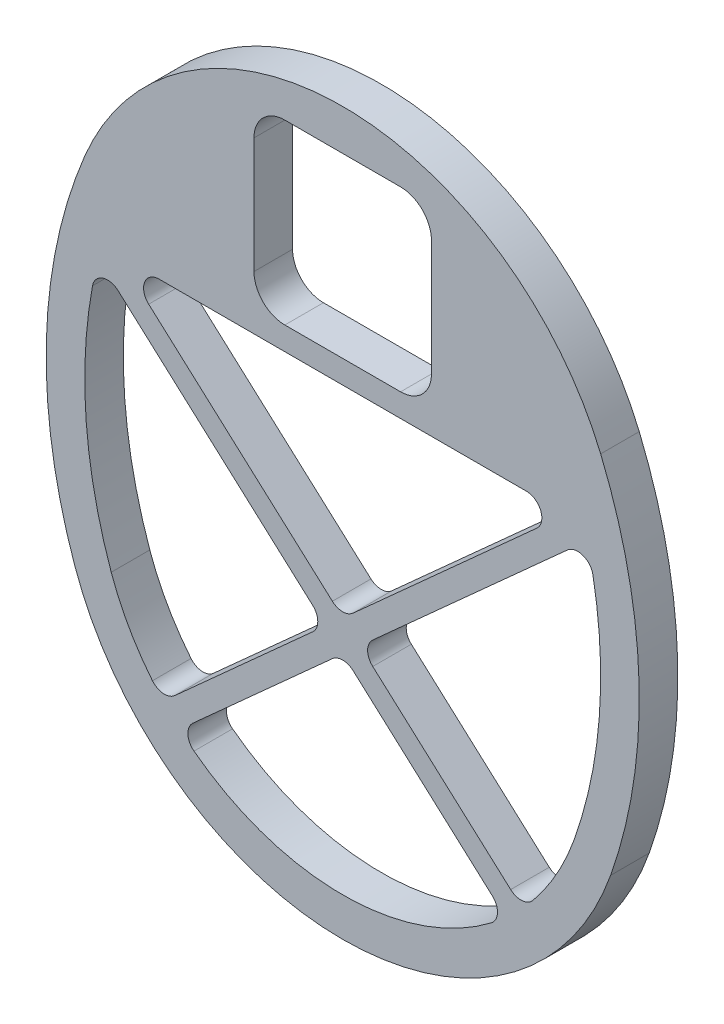
from build123d import *

# Parameters (mm, degrees)
BOSS_EXTRUDE1_DEPTH = 6.35
CUT_EXTRUDE1_REACH  = 8.35
SKETCH2_W           = 29.21
SKETCH2_H           = 29.21
FILLET1_R           = 5.08
BOSS_EXTRUDE2_DEPTH = 6.35
FILLET2_R           = 2.54


with BuildPart() as part:
    # Sketch1 → Boss-Extrude1 (new body)
    with BuildSketch(Plane.XY):
        with BuildLine():
            ThreePointArc((42.457951031, 57.15), (0, 85.455300688), (-42.457951031, 57.15))
            ThreePointArc((-42.457951031, 57.15), (-48.776790726, 27.667949622), (-44.086837414, -2.116666667))
            ThreePointArc((-44.086837414, -2.116666667), (0, -33.290768363), (44.086837414, -2.116666667))
            ThreePointArc((44.086837414, -2.116666667), (48.776790726, 27.667949622), (42.457951031, 57.15))
        make_face()
        with BuildLine():
            ThreePointArc((-38.1, 0), (-42.411411047, 22.737195516), (-39.698659089, 45.72))
            Line((-39.698659089, 45.72), (39.698659089, 45.72))
            ThreePointArc((39.698659089, 45.72), (42.411411047, 22.737195516), (38.1, 0))
            ThreePointArc((38.1, 0), (0, -26.940768363), (-38.1, 0))
        make_face(mode=Mode.SUBTRACT)
    extrude(amount=BOSS_EXTRUDE1_DEPTH)

    # Sketch2 → Cut-Extrude1 (cut, up to next)
    with BuildSketch(Plane.XY.offset(6.35), mode=Mode.PRIVATE) as cut_extrude1_sk1:
        with Locations((0, 64.135)):
            Rectangle(SKETCH2_W, SKETCH2_H)
    cut_extrude1_tool1 = extrude(cut_extrude1_sk1.sketch, amount=-CUT_EXTRUDE1_REACH, mode=Mode.PRIVATE) & part.part
    add(cut_extrude1_tool1.solids().sort_by_distance((0, 64.135, 6.35))[0], mode=Mode.SUBTRACT)

    # Fillet1
    fillet1_edges = [part.edges().sort_by_distance(p)[0] for p in [
        (14.605, 78.74, 3.175),
        (14.605, 49.53, 3.175),
        (-14.605, 49.53, 3.175),
        (-14.605, 78.74, 3.175),
    ]]
    fillet(fillet1_edges, radius=FILLET1_R)

    # Sketch3 → Boss-Extrude2 (add)
    with BuildSketch(Plane.XY.offset(6.35)):
        Polygon((-38.423965284, 47.135690893), (-40.973352894, 44.304309107), (-2.846977827, 9.975166803), (-31.416785414, -15.749203493), (-28.867397804, -18.580585278), (0, 7.411736453), (28.867397804, -18.580585278), (31.416785414, -15.749203493), (2.846977827, 9.975166803), (40.973352894, 44.304309107), (38.423965284, 47.135690893), (0, 12.538597153), align=None)
    extrude(amount=-BOSS_EXTRUDE2_DEPTH)

    # Fillet2
    fillet2_edges = [part.edges().sort_by_distance(p)[0] for p in [
        (-2.846977827, 9.975166803, 3.175),
        (2.846977827, 9.975166803, 3.175),
        (-40.241399563, 43.645255368, 3.175),
        (29.56358846, -14.08057746, 3.175),
        (26.831630213, -16.747571906, 3.175),
        (-36.851681262, 45.72, 3.175),
        (40.241399563, 43.645255368, 3.175),
        (36.851681262, 45.72, 3.175),
        (0, 12.538597153, 3.175),
        (-29.56358846, -14.08057746, 3.175),
        (-26.831630213, -16.747571906, 3.175),
        (0, 7.411736453, 3.175),
    ]]
    fillet(fillet2_edges, radius=FILLET2_R)


solid = part.part
